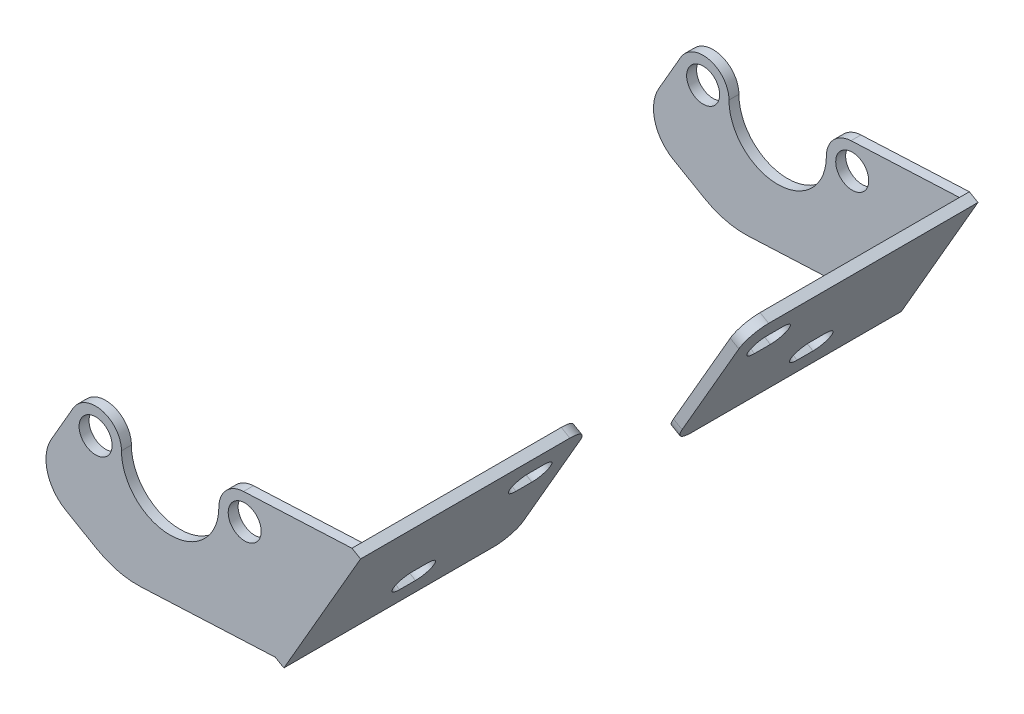
from build123d import *

# Parameters (mm, degrees)
SKETCH3_R           = 5.2705
BOSS_EXTRUDE1_DEPTH = 3.175
BOSS_EXTRUDE2_DEPTH = 70.05
FILLET1_R           = 12.7
FILLET3_R           = 25.4
SKETCH5_R           = 3.96875
CUT_EXTRUDE1_DEPTH  = 6.35
FILLET4_R           = 6.35


with BuildPart() as part:
    # Sketch3 → Boss-Extrude1 (new body)
    with BuildSketch(Plane.XY):
        with BuildLine():
            Line((-31.875, 1.314467847), (-31.875, 2.123689729))
            Line((-31.875, 2.123689729), (-44.309751158, -19.413931056))
            Line((-44.309751158, -19.413931056), (-16.813444588, -35.288931056))
            Line((-16.813444588, -35.288931056), (33.603324087, -32.943986013))
            Line((33.603324087, -32.943986013), (36.352954744, -34.531486013))
            Line((36.352954744, -34.531486013), (60.833371586, 7.869839748))
            Line((60.833371586, 7.869839748), (58.083740929, 9.457339748))
            Line((58.083740929, 9.457339748), (23.441464566, 7.84608547))
            ThreePointArc((23.441464566, 7.84608547), (28.824079828, 6.169187612), (31.875, 1.428257367))
            ThreePointArc((31.875, 1.428257367), (32.028589915, 0.519857326), (32.08, -0.4))
            ThreePointArc((32.08, -0.4), (32.028589915, -1.319857326), (31.875, -2.228257367))
            Line((31.875, -2.228257367), (31.875, -6.284053394))
            ThreePointArc((31.875, -6.284053394), (21.132205448, -10.12115273), (9.948783703, -12.371051434))
            ThreePointArc((9.948783703, -12.371051434), (0.015428746, -15.957499724), (-9.919275826, -12.374791656))
            ThreePointArc((-9.919275826, -12.374791656), (-21.117875037, -10.125129582), (-31.875, -6.284053394))
            Line((-31.875, -6.284053394), (-31.875, -2.114467847))
            ThreePointArc((-31.875, -2.114467847), (-32.055, -0.4), (-31.875, 1.314467847))
        make_face()
        with BuildLine():
            ThreePointArc((15.57, -0.4), (14.094750174, -7.012566542), (9.948783703, -12.371051434))
            ThreePointArc((9.948783703, -12.371051434), (21.132205448, -10.12115273), (31.875, -6.284053394))
            Line((31.875, -6.284053394), (31.875, -2.228257367))
            ThreePointArc((31.875, -2.228257367), (22.905142674, -8.603589915), (15.57, -0.4))
        make_face()
        with BuildLine():
            ThreePointArc((23.441464566, 7.84608547), (17.853772739, 5.299953508), (15.57, -0.4))
            ThreePointArc((15.57, -0.4), (22.905142674, -8.603589915), (31.875, -2.228257367))
            Line((31.875, -2.228257367), (31.875, 1.428257367))
            ThreePointArc((31.875, 1.428257367), (28.824079828, 6.169187612), (23.441464566, 7.84608547))
        make_face()
        with Locations((23.825, -0.4)):
            Circle(SKETCH3_R, mode=Mode.SUBTRACT)
        with BuildLine():
            ThreePointArc((-9.919275826, -12.374791656), (-14.068505089, -7.015217451), (-15.545, -0.4))
            ThreePointArc((-15.545, -0.4), (-22.938054526, -8.609876674), (-31.875, -2.114467847))
            Line((-31.875, -2.114467847), (-31.875, -6.284053394))
            ThreePointArc((-31.875, -6.284053394), (-21.117875037, -10.125129582), (-9.919275826, -12.374791656))
        make_face()
        with BuildLine():
            ThreePointArc((-15.545, -0.4), (-21.663448783, 7.573717696), (-30.949039708, 3.7275))
            ThreePointArc((-30.949039708, 3.7275), (-31.507044005, 2.557447835), (-31.875, 1.314467847))
            Line((-31.875, 1.314467847), (-31.875, -2.114467847))
            ThreePointArc((-31.875, -2.114467847), (-22.938054526, -8.609876674), (-15.545, -0.4))
        make_face()
        with Locations((-23.8, -0.4)):
            Circle(SKETCH3_R, mode=Mode.SUBTRACT)
        with BuildLine():
            Line((31.875, 1.428257367), (31.875, -2.228257367))
            ThreePointArc((31.875, -2.228257367), (32.028589915, -1.319857326), (32.08, -0.4))
            ThreePointArc((32.08, -0.4), (32.028589915, 0.519857326), (31.875, 1.428257367))
        make_face()
        with BuildLine():
            Line((-31.875, -2.114467847), (-31.875, 1.314467847))
            ThreePointArc((-31.875, 1.314467847), (-32.055, -0.4), (-31.875, -2.114467847))
        make_face()
        with BuildLine():
            ThreePointArc((-31.875, 1.314467847), (-31.507044005, 2.557447835), (-30.949039708, 3.7275))
            Line((-30.949039708, 3.7275), (-31.875, 2.123689729))
            Line((-31.875, 2.123689729), (-31.875, 1.314467847))
        make_face()
    extrude(amount=BOSS_EXTRUDE1_DEPTH)

    # Sketch4 → Boss-Extrude2 (add)
    with BuildSketch(Plane.XY.offset(3.175)):
        Polygon((60.833371586, 7.869839748), (36.352954744, -34.531486013), (33.603324087, -32.943986013), (58.083740929, 9.457339748), align=None)
    extrude(amount=BOSS_EXTRUDE2_DEPTH)

    # Fillet1
    fillet1_edges = [part.edges().sort_by_distance(p)[0] for p in [
        (-44.309751158, -19.413931056, 1.5875),
    ]]
    fillet(fillet1_edges, radius=FILLET1_R)

    # Fillet3
    fillet3_edges = [part.edges().sort_by_distance(p)[0] for p in [
        (-16.813444588, -35.288931056, 1.5875),
    ]]
    fillet(fillet3_edges, radius=FILLET3_R)

    # Sketch5 → Cut-Extrude1 (cut)
    with BuildSketch(Plane(origin=(39.46765746, -22.786662659, 0), x_dir=(0, 0, 1), z_dir=(-0.866025404, 0.5, 0))):
        with Locations((37.665, 0.971333254)):
            Circle(SKETCH5_R)
        with Locations((32.585, 0.971333254)):
            Circle(SKETCH5_R)
        with BuildLine():
            Line((37.665, 4.940083254), (32.585, 4.940083254))
            ThreePointArc((32.585, 4.940083254), (33.935614932, 4.703198186), (35.125, 4.020821172))
            ThreePointArc((35.125, 4.020821172), (36.314385068, 4.703198186), (37.665, 4.940083254))
        make_face()
        with BuildLine():
            ThreePointArc((35.125, -2.078154664), (33.935614932, -2.760531678), (32.585, -2.997416746))
            Line((32.585, -2.997416746), (37.665, -2.997416746))
            ThreePointArc((37.665, -2.997416746), (36.314385068, -2.760531678), (35.125, -2.078154664))
        make_face()
        with Locations((63.065, 24.532166939)):
            Circle(SKETCH5_R)
        with Locations((57.985, 24.532166939)):
            Circle(SKETCH5_R)
        with BuildLine():
            Line((63.065, 28.500916939), (57.985, 28.500916939))
            ThreePointArc((57.985, 28.500916939), (59.335614932, 28.26403187), (60.525, 27.581654857))
            ThreePointArc((60.525, 27.581654857), (61.714385068, 28.26403187), (63.065, 28.500916939))
        make_face()
        with BuildLine():
            ThreePointArc((60.525, 21.482679021), (59.335614932, 20.800302007), (57.985, 20.563416939))
            Line((57.985, 20.563416939), (63.065, 20.563416939))
            ThreePointArc((63.065, 20.563416939), (61.714385068, 20.800302007), (60.525, 21.482679021))
        make_face()
    extrude(amount=-CUT_EXTRUDE1_DEPTH, mode=Mode.SUBTRACT)

    # Fillet4
    fillet4_edges = [part.edges().sort_by_distance(p)[0] for p in [
        (34.978139415, -33.737736013, 73.225),
        (59.458556258, 8.663589748, 73.225),
    ]]
    fillet(fillet4_edges, radius=FILLET4_R)


with BuildPart() as body_2:
    # Mirror3: mirrored copy
    add(part.part.mirror(Plane.XY.offset(98.625)))


solid = Compound([part.part, body_2.part])
